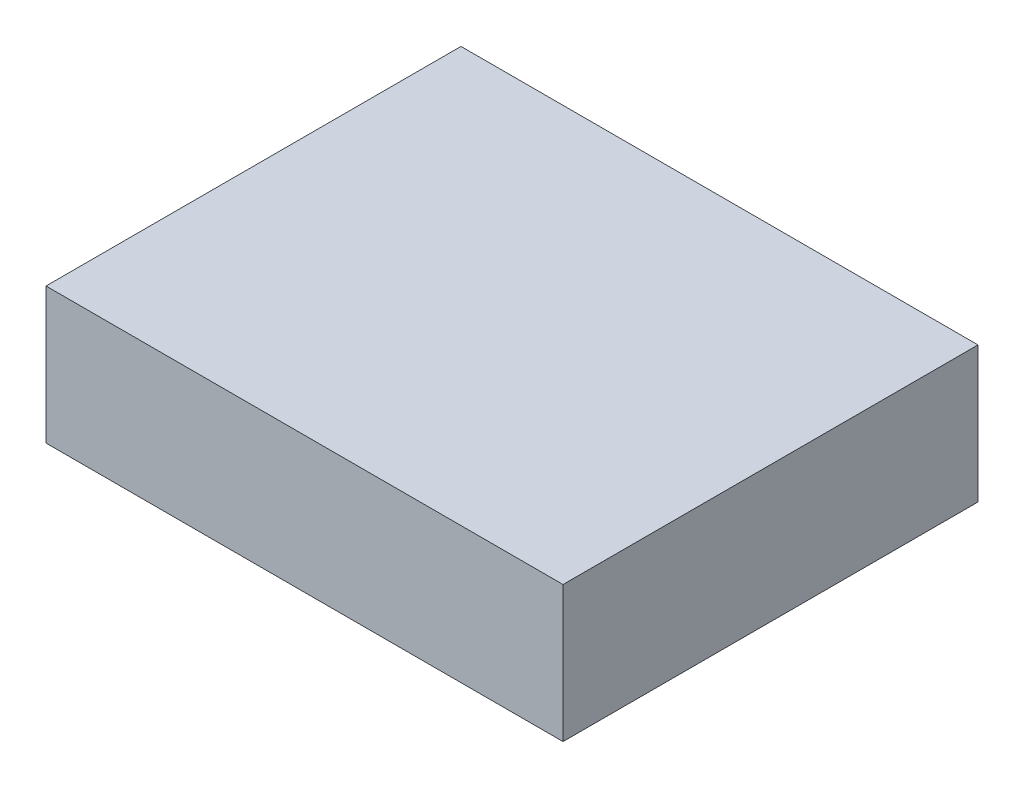
from build123d import *

# Parameters (mm, degrees)
SKETCH1_W           = 76
SKETCH1_H           = 61
BOSS_EXTRUDE1_DEPTH = 20


with BuildPart() as part:
    # Sketch1 → Boss-Extrude1 (new body)
    with BuildSketch(Plane(origin=(0, 0, 0), x_dir=(1, 0, 0), z_dir=(0, 1, 0))):
        with Locations((9.27077748, -15.269436997)):
            Rectangle(SKETCH1_W, SKETCH1_H)
    extrude(amount=BOSS_EXTRUDE1_DEPTH)


solid = part.part
